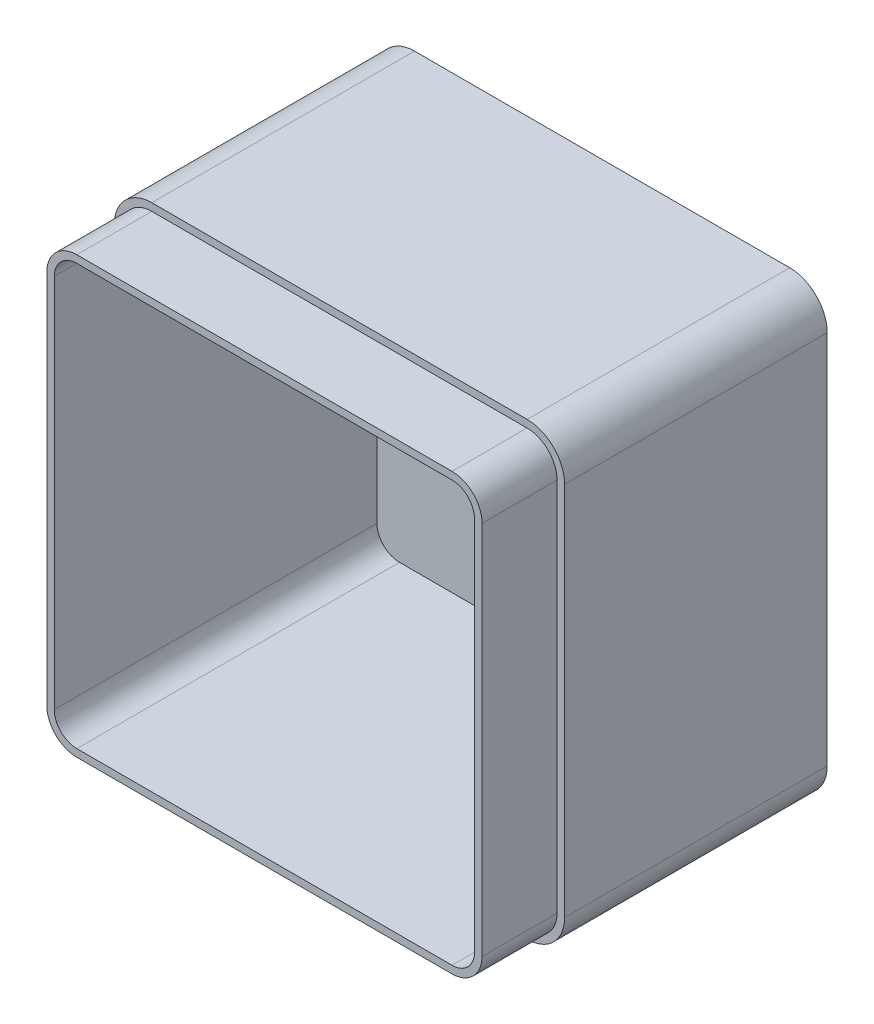
from build123d import *

# Parameters (mm, degrees)
SKETCH1_W           = 120
SKETCH1_H           = 120
BOSS_EXTRUDE1_DEPTH = 90
FILLET1_R           = 10
SHELL1_T            = -4
CUT_EXTRUDE1_DEPTH  = 20


with BuildPart() as part:
    # Sketch1 → Boss-Extrude1 (new body)
    with BuildSketch(Plane.XY):
        with Locations((60, 60)):
            Rectangle(SKETCH1_W, SKETCH1_H)
    extrude(amount=BOSS_EXTRUDE1_DEPTH)

    # Fillet1
    fillet1_edges = [part.edges().sort_by_distance(p)[0] for p in [
        (0, 120, 45),
        (120, 120, 45),
        (120, 0, 45),
        (0, 0, 45),
    ]]
    fillet(fillet1_edges, radius=FILLET1_R)

    # Shell1
    shell1_openings = [part.faces().sort_by_distance(p)[0] for p in [
        (60, 60, 90),
    ]]
    offset(amount=SHELL1_T, openings=shell1_openings, kind=Kind.INTERSECTION)

    # Sketch3 → Cut-Extrude1 (cut)
    with BuildSketch(Plane.XY.offset(90)):
        with BuildLine():
            Line((0, 110), (0, 10))
            ThreePointArc((0, 10), (2.928932188, 2.928932188), (10, 0))
            Line((10, 0), (110, 0))
            ThreePointArc((110, 0), (117.071067812, 2.928932188), (120, 10))
            Line((120, 10), (120, 110))
            ThreePointArc((120, 110), (117.071067812, 117.071067812), (110, 120))
            Line((110, 120), (10, 120))
            ThreePointArc((10, 120), (2.928932188, 117.071067812), (0, 110))
        make_face()
        with BuildLine():
            Line((2, 110), (2, 10))
            ThreePointArc((2, 10), (4.343145751, 4.343145751), (10, 2))
            Line((10, 2), (110, 2))
            ThreePointArc((110, 2), (115.656854249, 4.343145751), (118, 10))
            Line((118, 10), (118, 110))
            ThreePointArc((118, 110), (115.656854249, 115.656854249), (110, 118))
            Line((110, 118), (10, 118))
            ThreePointArc((10, 118), (4.343145751, 115.656854249), (2, 110))
        make_face(mode=Mode.SUBTRACT)
    extrude(amount=-CUT_EXTRUDE1_DEPTH, mode=Mode.SUBTRACT)


solid = part.part
